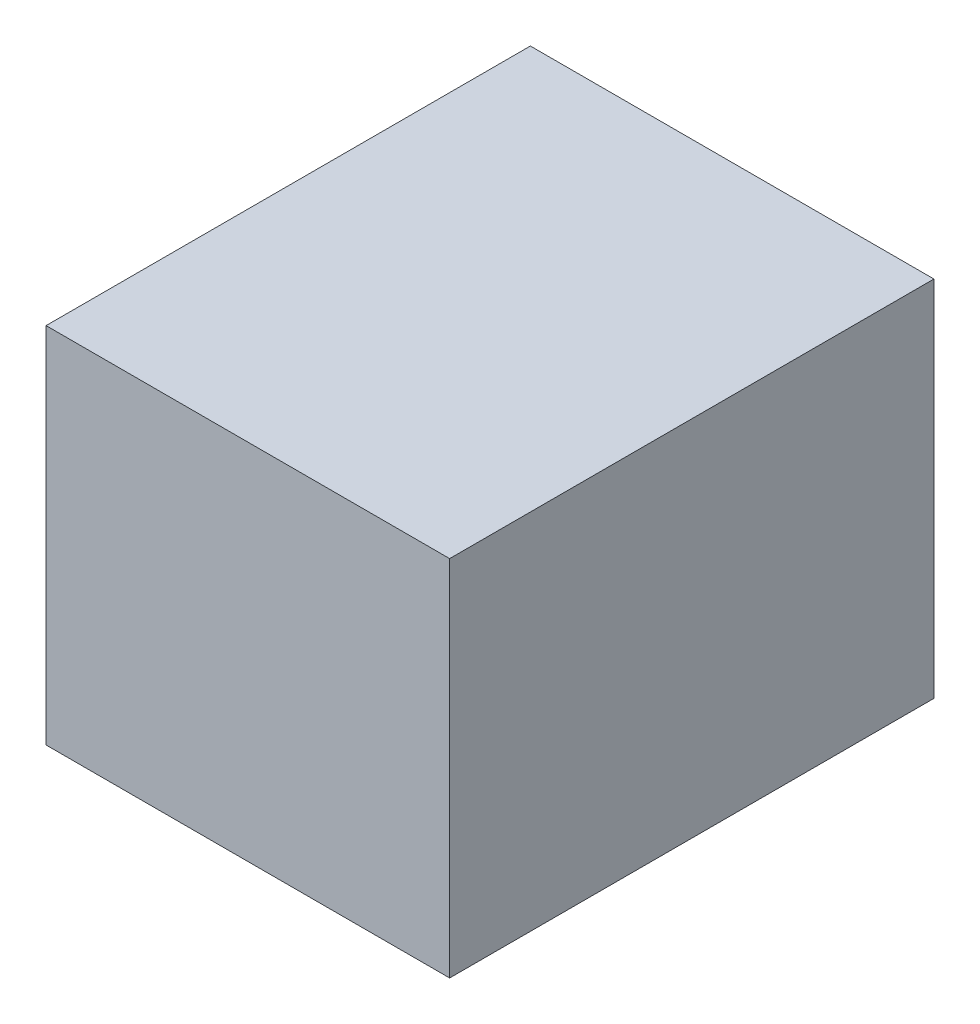
from build123d import *

# Parameters (mm, degrees)
SKETCH1_W           = 500
SKETCH1_H           = 600
BOSS_EXTRUDE1_DEPTH = 450
SKETCH2_W           = 550
SKETCH2_H           = 200
SKETCH2_H_2         = 175
CUT_EXTRUDE2_DEPTH  = 475


with BuildPart() as part:
    # Sketch1 → Boss-Extrude1 (new body)
    with BuildSketch(Plane(origin=(0, 0, 0), x_dir=(1, 0, 0), z_dir=(0, 1, 0))):
        with Locations((250, 300)):
            Rectangle(SKETCH1_W, SKETCH1_H)
    extrude(amount=BOSS_EXTRUDE1_DEPTH)

    # Sketch2 → Cut-Extrude2 (cut)
    with BuildSketch(Plane.ZY):
        with Locations((-300, 325)):
            Rectangle(SKETCH2_W, SKETCH2_H)
        with Locations((-300, 112.5)):
            Rectangle(SKETCH2_W, SKETCH2_H_2)
    extrude(amount=-CUT_EXTRUDE2_DEPTH, mode=Mode.SUBTRACT)


solid = part.part
